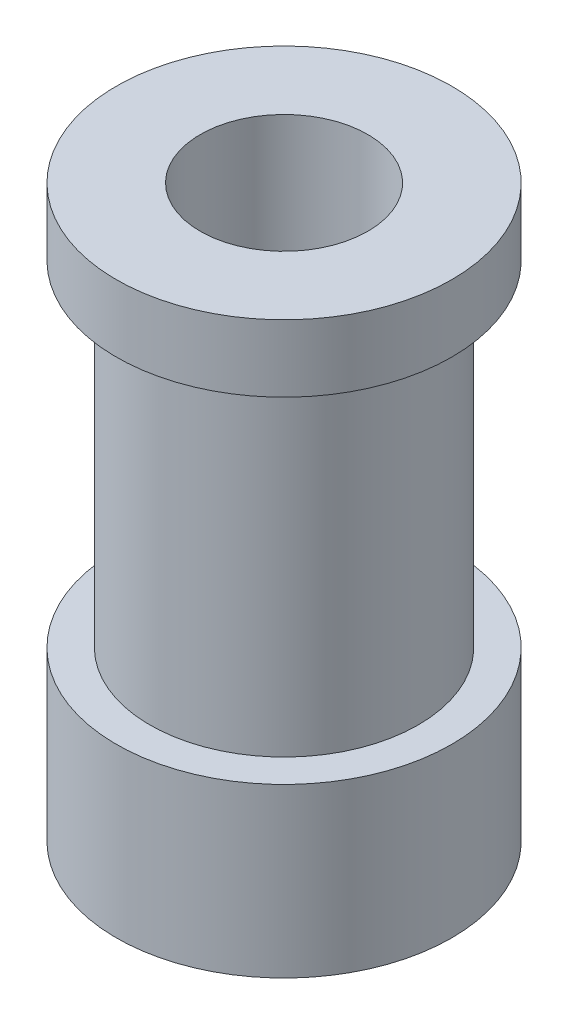
from build123d import *

# Parameters (mm, degrees)
SKETCH3_R          = 1
CUT_EXTRUDE1_DEPTH = 10
SKETCH4_R          = 1
CUT_EXTRUDE2_DEPTH = 10


with BuildPart() as part:
    # Sketch1 → Revolve1 (revolve)
    with BuildSketch(Plane.XY):
        Polygon((2.5, 0), (5, 0), (5, 5), (4, 5), (4, 15), (5, 15), (5, 17), (2.5, 17), align=None)
    revolve(axis=Axis((0, 0, 0), (0, 1, 0)))

    # Sketch3 → Cut-Extrude1 (cut)
    with BuildSketch(Plane.XY):
        with Locations((0, 2.5)):
            Circle(SKETCH3_R)
    extrude(amount=-CUT_EXTRUDE1_DEPTH, mode=Mode.SUBTRACT)

    # Sketch4 → Cut-Extrude2 (cut)
    with BuildSketch(Plane(origin=(0, 0, 0), x_dir=(0, 0, -1), z_dir=(1, 0, 0))):
        with Locations((0, 2.5)):
            Circle(SKETCH4_R)
    extrude(amount=-CUT_EXTRUDE2_DEPTH, mode=Mode.SUBTRACT)


solid = part.part
